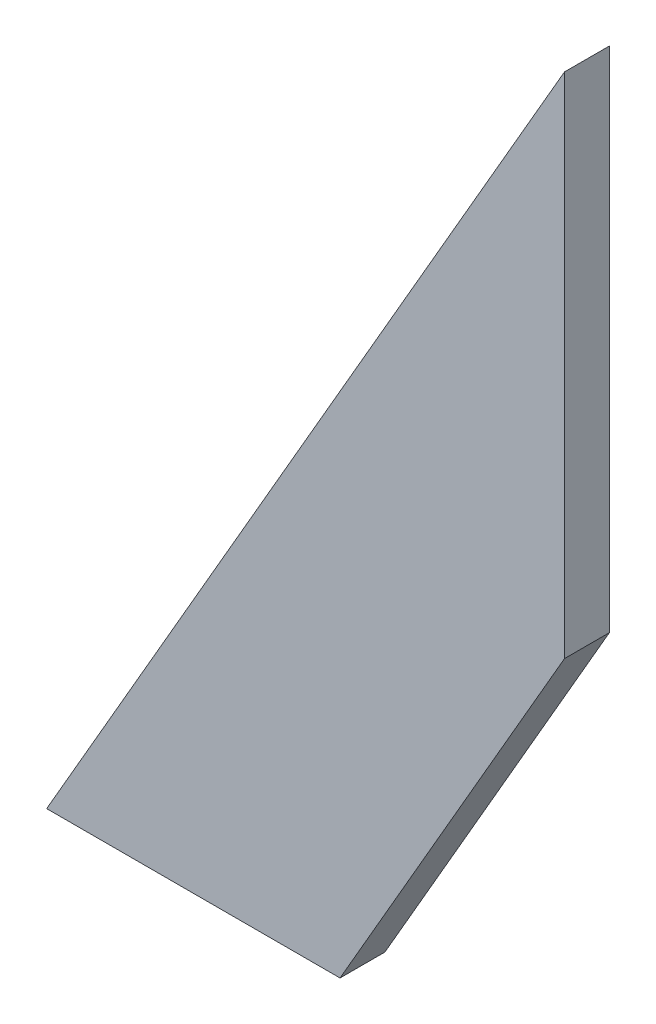
from build123d import *

# Parameters (mm, degrees)
BOSS_EXTRUDE1_DEPTH = 3


with BuildPart() as part:
    # Sketch1 → Boss-Extrude1 (new body)
    with BuildSketch(Plane.XY):
        Polygon((-258.656795041, 260.556752989), (-258.656795041, 226.562169331), (-273.676029688, 200.545305077), (-293.304420647, 200.545305077), align=None)
    extrude(amount=BOSS_EXTRUDE1_DEPTH)


solid = part.part
